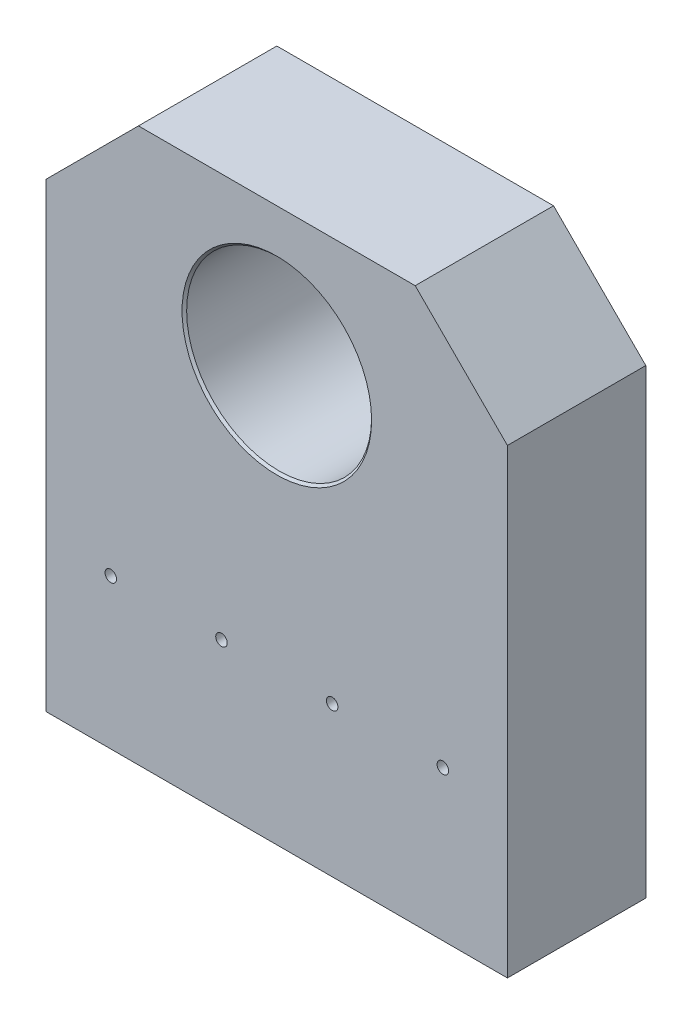
from build123d import *

# Parameters (mm, degrees)
SKETCH1_W                         = 127
SKETCH1_H                         = 152.4
EXTRUDE1_DEPTH                    = 38.1
CHAMFER1_SIZE                     = 25.4
F_1_2_13_TAPPED_HOLE1_D           = 10.71626
F_1_2_13_TAPPED_HOLE1_DEPTH       = 44.45
F_1_2_13_TAPPED_HOLE1_CSINK_D     = 13.462
F_1_2_13_TAPPED_HOLE1_CSINK_ANGLE = 90
F_1_2_13_TAPPED_HOLE1_TIP         = 3.219489309
SKETCH4_R                         = 1.5875
CUT_EXTRUDE1_DEPTH                = 39.1


with BuildPart() as part:
    # Sketch1 → Extrude1 (new body)
    with BuildSketch(Plane.XY):
        with Locations((63.5, 76.2)):
            Rectangle(SKETCH1_W, SKETCH1_H)
    extrude(amount=EXTRUDE1_DEPTH)

    # Sketch5 → 1 (1) Diameter Hole1 (revolve, cut)
    with BuildSketch(Plane(origin=(63.5, 114.3, 38.1), x_dir=(0, -1, 0), z_dir=(1, 0, 0))):
        Polygon((0, 0), (0, 38.1), (26.0985, 38.1), (25.4635, 37.465), (25.4635, 0.635), (26.0985, 0), align=None)
    revolve(axis=Axis((63.5, 114.3, 44.45), (0, 0, -1)), mode=Mode.SUBTRACT)

    # Chamfer1
    chamfer1_edges = [part.edges().sort_by_distance(p)[0] for p in [
        (0, 152.4, 19.05),
        (127, 152.4, 19.05),
    ]]
    chamfer(chamfer1_edges, length=CHAMFER1_SIZE)

    # 1/2-13 Tapped Hole1
    with Locations(Plane(origin=(109.22, 0, 25.4), x_dir=(0, 0, -1), z_dir=(0, -1, 0))):
        with Locations((0, 0), (0, -30.48), (0, -60.96), (0, -91.44)):
            CounterSinkHole(F_1_2_13_TAPPED_HOLE1_D / 2, F_1_2_13_TAPPED_HOLE1_CSINK_D / 2, depth=F_1_2_13_TAPPED_HOLE1_DEPTH, counter_sink_angle=F_1_2_13_TAPPED_HOLE1_CSINK_ANGLE)
            with Locations((0, 0, -(F_1_2_13_TAPPED_HOLE1_DEPTH + F_1_2_13_TAPPED_HOLE1_TIP / 2))):  # 118° drill point
                Cone(0, F_1_2_13_TAPPED_HOLE1_D / 2, F_1_2_13_TAPPED_HOLE1_TIP, mode=Mode.SUBTRACT)

    # Sketch4 → Cut-Extrude1 (cut, through all)
    with BuildSketch(Plane.XY.offset(38.1)):
        with Locations((17.78, 41.275)):
            Circle(SKETCH4_R)
        with Locations((48.26, 41.275)):
            Circle(SKETCH4_R)
        with Locations((78.74, 41.275)):
            Circle(SKETCH4_R)
        with Locations((109.22, 41.275)):
            Circle(SKETCH4_R)
    extrude(amount=-CUT_EXTRUDE1_DEPTH, mode=Mode.SUBTRACT)


solid = part.part
